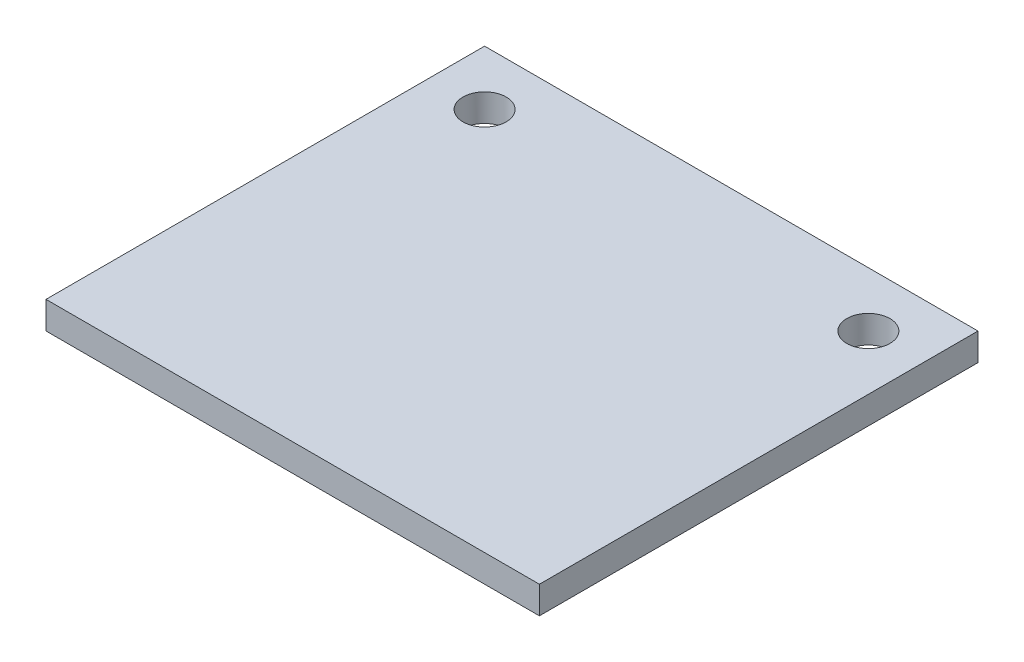
from build123d import *

# Parameters (mm, degrees)
SKETCH1_W               = 22.86
SKETCH1_H               = 20.32
BOSS_EXTRUDE1_DEPTH     = 0.635
SKETCH2_R               = 1
CUT_EXTRUDE1_DEPTH      = 1
CUT_EXTRUDE1_DEPTH_BACK = 2.27


with BuildPart() as part:
    # Sketch1 → Boss-Extrude1 (new body, symmetric)
    with BuildSketch(Plane(origin=(0, 0, 0), x_dir=(1, 0, 0), z_dir=(0, 1, 0))):
        Rectangle(SKETCH1_W, SKETCH1_H)
    extrude(amount=BOSS_EXTRUDE1_DEPTH, both=True)

    # Sketch2 → Cut-Extrude1 (cut, two sides)
    with BuildSketch(Plane(origin=(0, 0.635, 0), x_dir=(1, 0, 0), z_dir=(0, 1, 0))) as cut_extrude1_sk:
        with Locations((-8.89, 7.62)):
            Circle(SKETCH2_R)
        with Locations((8.89, 7.62)):
            Circle(SKETCH2_R)
    extrude(amount=CUT_EXTRUDE1_DEPTH, mode=Mode.SUBTRACT)
    extrude(cut_extrude1_sk.sketch, amount=-CUT_EXTRUDE1_DEPTH_BACK, mode=Mode.SUBTRACT)


solid = part.part
